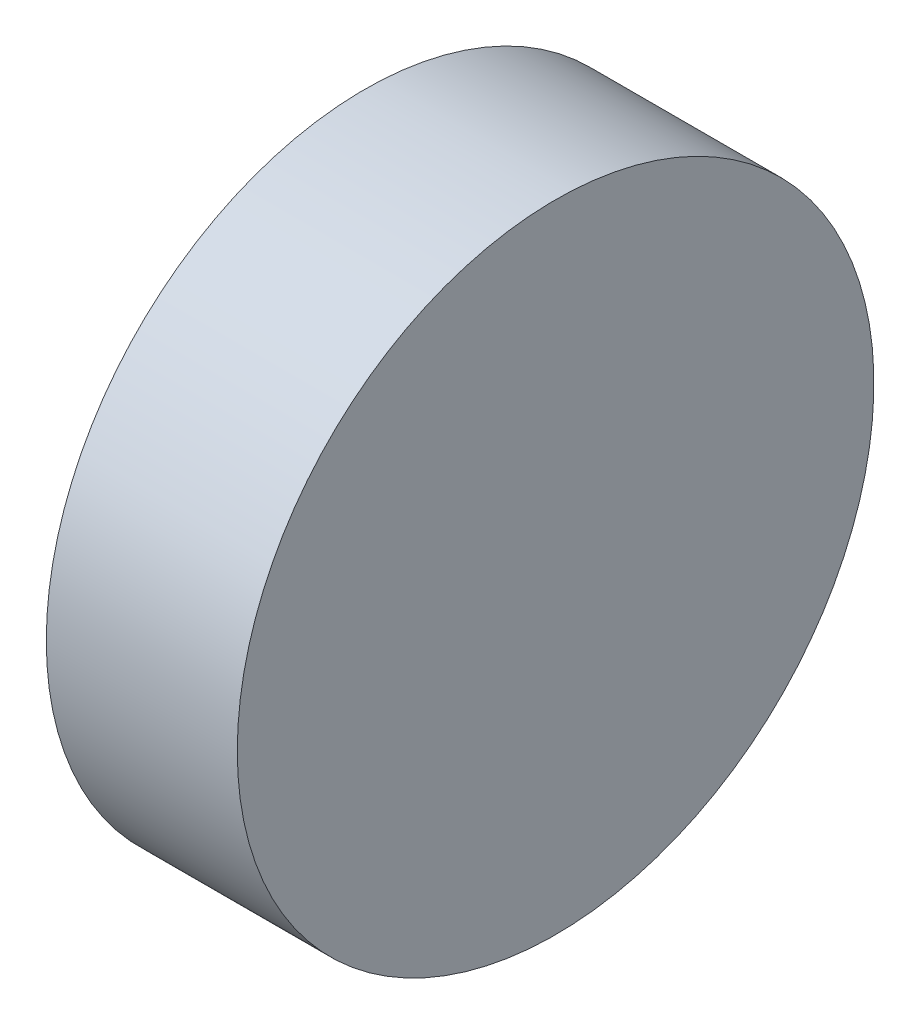
from build123d import *

# Parameters (mm, degrees)
SKETCH_1_W = 5.999999994
SKETCH_1_H = 9.99999999


with BuildPart() as part:
    # 草图1 → 旋转1 (revolve)
    with BuildSketch(Plane.XY, mode=Mode.PRIVATE) as revolve_1_sk:
        with Locations((176.41866453, 56.528786176)):
            Rectangle(SKETCH_1_W, SKETCH_1_H)
    revolve(revolve_1_sk.sketch.rotate(Axis((169.333867826, 51.528786181, 0), (1, 0, 0)), 90), axis=Axis((169.333867826, 51.528786181, 0), (1, 0, 0)))  # turned: the seam where the file's is


solid = part.part
